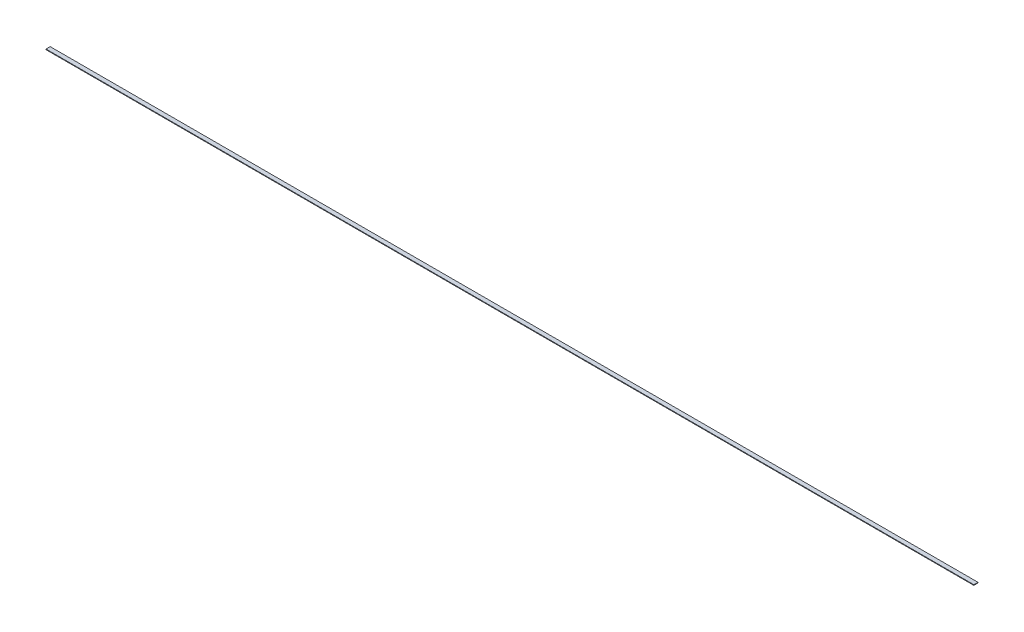
from build123d import *

# Parameters (mm, degrees)
SKETCH1_W           = 5.55625
SKETCH1_H           = 0.79375
BOSS_EXTRUDE1_DEPTH = 1236.6625


with BuildPart() as part:
    # Sketch1 → Boss-Extrude1 (new body)
    with BuildSketch(Plane(origin=(0, 0, 0), x_dir=(0, 0, -1), z_dir=(1, 0, 0))):
        with Locations((2.778125, 0.396875)):
            Rectangle(SKETCH1_W, SKETCH1_H)
    extrude(amount=BOSS_EXTRUDE1_DEPTH)


solid = part.part
